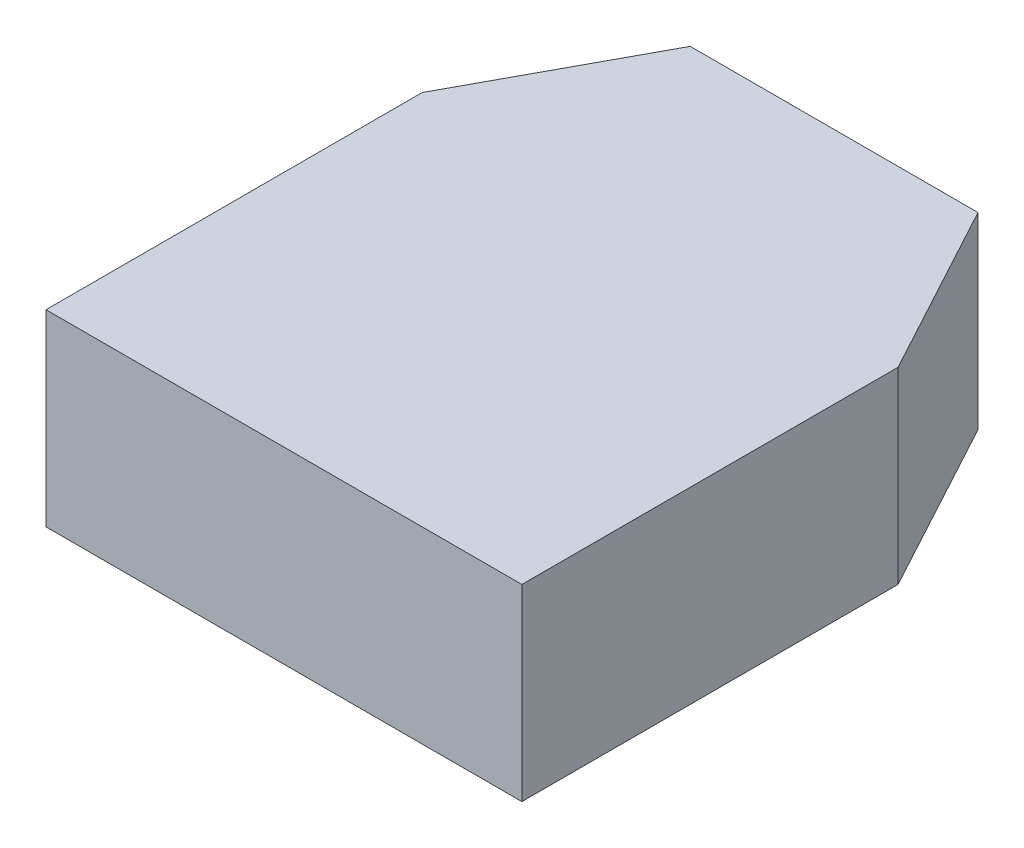
from build123d import *

# Parameters (mm, degrees)
BOSS_EXTRUDE1_DEPTH = 20


with BuildPart() as part:
    # Sketch1 → Boss-Extrude1 (new body)
    with BuildSketch(Plane(origin=(0, 0, 0), x_dir=(1, 0, 0), z_dir=(0, 1, 0))):
        Polygon((-50.6, 40), (-40.6, 58.5), (-10, 58.5), (0, 40), (0, 0), (-50.6, 0), align=None)
    extrude(amount=BOSS_EXTRUDE1_DEPTH)


solid = part.part
